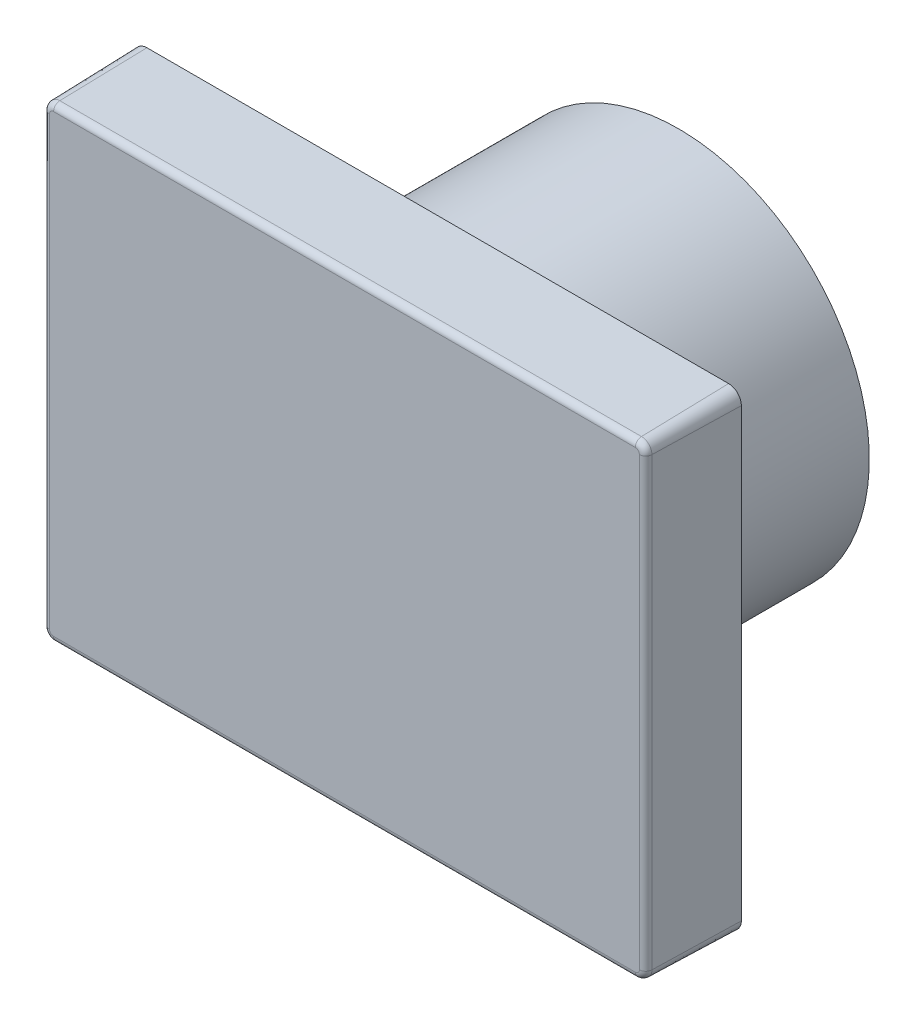
from build123d import *

# Parameters (mm, degrees)
SKETCH1_W           = 60.5
SKETCH1_H           = 47
BOSS_EXTRUDE1_DEPTH = 9.3
FILLET1_R           = 1.27
DRAFT1_ANGLE        = -1.5
FILLET2_R           = 0.635
SKETCH3_R           = 19
BOSS_EXTRUDE2_DEPTH = 24
SKETCH4_R           = 2
BOSS_EXTRUDE3_DEPTH = 4


with BuildPart() as part:
    # Sketch1 → Boss-Extrude1 (new body)
    with BuildSketch(Plane.XY):
        Rectangle(SKETCH1_W, SKETCH1_H)
    extrude(amount=BOSS_EXTRUDE1_DEPTH)

    # Fillet1
    fillet1_edges = [part.edges().sort_by_distance(p)[0] for p in [
        (30.25, -23.5, 4.65),
        (-30.25, -23.5, 4.65),
        (-30.25, 23.5, 4.65),
        (30.25, 23.5, 4.65),
    ]]
    fillet(fillet1_edges, radius=FILLET1_R)

    # Draft1
    draft1_faces = [part.faces().sort_by_distance(p)[0] for p in [
        (-29.878025612, -23.128025612, 4.65),
        (0, -23.5, 4.65),
        (29.878025612, -23.128025612, 4.65),
        (30.25, 0, 4.65),
        (29.878025612, 23.128025612, 4.65),
        (0, 23.5, 4.65),
        (-30.25, 0, 4.65),
        (-29.878025612, 23.128025612, 4.65),
    ]]
    draft(draft1_faces, Plane(origin=(0, 0, 0), x_dir=(-1, 0, 0), z_dir=(0, 0, -1)), DRAFT1_ANGLE)

    # Fillet2
    fillet2_edges = [part.edges().sort_by_distance(p)[0] for p in [
        (0, -23.256470929, 9.3),
        (-30.006470929, 0, 9.3),
        (30.006470929, 0, 9.3),
        (0, 23.256470929, 9.3),
        (-29.705824555, 22.955824555, 9.3),
        (29.705824555, 22.955824555, 9.3),
        (29.705824555, -22.955824555, 9.3),
        (-29.705824555, -22.955824555, 9.3),
    ]]
    fillet(fillet2_edges, radius=FILLET2_R)

    # Sketch3 → Boss-Extrude2 (add)
    with BuildSketch(Plane(origin=(0, 0, 0), x_dir=(-1, 0, 0), z_dir=(0, 0, -1))):
        Circle(SKETCH3_R)
    extrude(amount=BOSS_EXTRUDE2_DEPTH)

    # Sketch4 → Boss-Extrude3 (add)
    with BuildSketch(Plane(origin=(0, 0, -24), x_dir=(-1, 0, 0), z_dir=(0, 0, -1))):
        Circle(SKETCH4_R)
    extrude(amount=BOSS_EXTRUDE3_DEPTH)


solid = part.part
